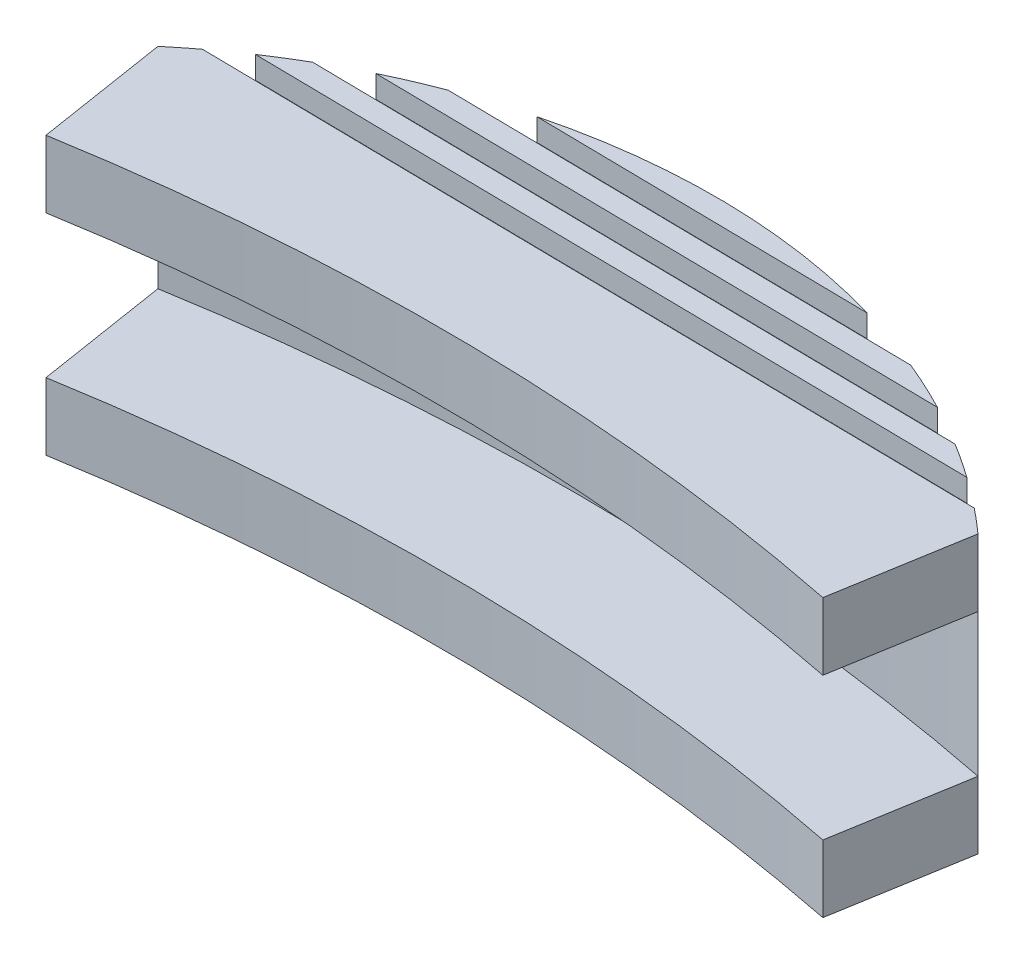
from build123d import *

# Parameters (mm, degrees)
BOSS_EXTRUDE1_DEPTH = 3
BOSS_EXTRUDE2_START = -6.36
BOSS_EXTRUDE2_DEPTH = 3
BOSS_EXTRUDE3_START = -3
BOSS_EXTRUDE3_DEPTH = 12.36
CUT_EXTRUDE1_DEPTH  = 1


with BuildPart() as part:
    # Sketch1 → Boss-Extrude1 (new body)
    with BuildSketch(Plane.XZ.offset(32.361588827)):
        with BuildLine():
            Line((-28.868957331, -307.014773368), (-29.868957331, -301.096085324))
            ThreePointArc((-29.868957331, -301.096085324), (-47.432277428, -302.971340874), (-65.04446736, -301.630608989))
            Line((-65.04446736, -301.630608989), (-65.981716568, -307.557257918))
            ThreePointArc((-65.981716568, -307.557257918), (-47.400699357, -308.971536481), (-28.868957331, -307.014773368))
        make_face()
    extrude(amount=BOSS_EXTRUDE1_DEPTH)



with BuildPart() as body_2:
    # Sketch1_2 → Boss-Extrude2 (new body)
    with BuildSketch(Plane.XZ.offset(32.361588827).offset(BOSS_EXTRUDE2_START)):
        with BuildLine():
            Line((-28.868957331, -307.014773368), (-29.868957331, -301.096085324))
            ThreePointArc((-29.868957331, -301.096085324), (-47.432277428, -302.971340874), (-65.04446736, -301.630608989))
            Line((-65.04446736, -301.630608989), (-65.981716568, -307.557257918))
            ThreePointArc((-65.981716568, -307.557257918), (-47.400699357, -308.971536481), (-28.868957331, -307.014773368))
        make_face()
    extrude(amount=-BOSS_EXTRUDE2_DEPTH)


with BuildPart() as part_1:
    add(part.part)

    add(body_2.part)  # Boss-Extrude3 merges body 2
    # Sketch2 → Boss-Extrude3 (add)
    with BuildSketch(Plane(origin=(0, -26.001588827, 0), x_dir=(-1, 0, 0), z_dir=(0, -1, 0)).offset(BOSS_EXTRUDE3_START)):
        with BuildLine():
            ThreePointArc((65.981716568, 307.557257918), (47.400699357, 308.971536481), (28.868957331, 307.014773368))
            ThreePointArc((28.868957331, 307.014773368), (47.324504287, 314.184236637), (65.981716568, 307.557257918))
        make_face()
    extrude(amount=BOSS_EXTRUDE3_DEPTH)

    # Sketch4 → Cut-Extrude1 (cut)
    with BuildSketch(Plane(origin=(0, -23.001588827, 0), x_dir=(1, 0, 0), z_dir=(0, 1, 0))):
        with BuildLine():
            ThreePointArc((-63.492663367, 309.420035692), (-64.18989584, 308.940344318), (-64.87253134, 308.44009867))
            Line((-64.87253134, 308.44009867), (-29.951864875, 307.929656373))
            ThreePointArc((-29.951864875, 307.929656373), (-30.619587474, 308.449640474), (-31.302501574, 308.949505723))
            Line((-31.302501574, 308.949505723), (-63.492663367, 309.420035692))
        make_face()
        with BuildLine():
            ThreePointArc((-60.073849839, 311.370275869), (-61.00439253, 310.900603204), (-61.917080112, 310.397111905))
            Line((-61.917080112, 310.397111905), (-32.848853555, 309.972215882))
            ThreePointArc((-32.848853555, 309.972215882), (-33.746435087, 310.502168243), (-34.662852555, 310.99883829))
            Line((-34.662852555, 310.99883829), (-60.073849839, 311.370275869))
        make_face()
        with BuildLine():
            ThreePointArc((-54.80969362, 313.293542306), (-56.329988828, 312.857479245), (-57.823662491, 312.33749126))
            Line((-57.823662491, 312.33749126), (-36.88380863, 312.03140927))
            ThreePointArc((-36.88380863, 312.03140927), (-38.361645858, 312.594832417), (-39.868546228, 313.075144596))
            Line((-39.868546228, 313.075144596), (-54.80969362, 313.293542306))
        make_face()
    cut_extrude1 = extrude(amount=-CUT_EXTRUDE1_DEPTH, mode=Mode.SUBTRACT)

    # Mirror1: Cut-Extrude1 across plane
    add(cut_extrude1.mirror(Plane(origin=(0, -29.181588827, 0), x_dir=(0, 0, 1), z_dir=(0, -1, 0))), mode=Mode.SUBTRACT)


solid = part_1.part
